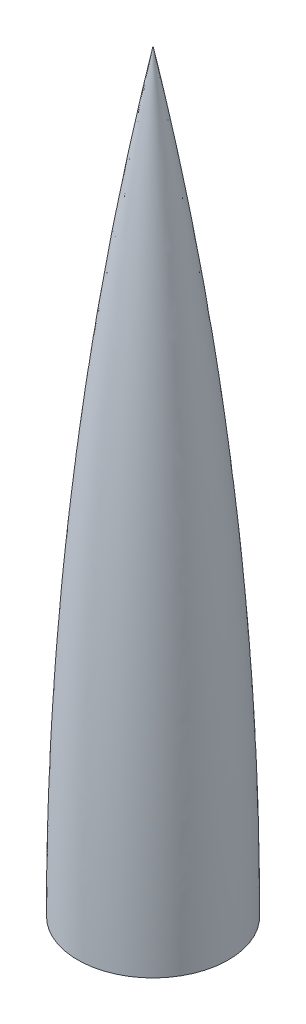
from build123d import *


with BuildPart() as part:
    # Sketch1 → Revolve1 (revolve)
    with BuildSketch(Plane(origin=(0, 0, 0), x_dir=(0, 0, -1), z_dir=(1, 0, 0))):
        with BuildLine():
            Line((76.2, 0), (78.359, 0))
            add(Edge.make_bspline(
                [(74.5236, 173.99), (77.07256008, 116.0310849), (78.349261293, 58.01558305), (78.359, 0)],
                knots=[0.779357411, 0.779357411, 0.779357411, 0.779357411, 1, 1, 1, 1], degree=3))
            Line((74.5236, 173.99), (72.834586455, 173.99))
            add(Edge.make_bspline(
                [(72.834586455, 173.99), (75.070189235, 115.962788806), (75.922551541, 57.867863687), (76.2, 0)],
                knots=[0.776751373, 0.776751373, 0.776751373, 0.776751373, 1, 1, 1, 1], degree=3))
        make_face()
        with BuildLine():
            Line((72.834586455, 173.99), (74.5236, 173.99))
            add(Edge.make_bspline(
                [(64.8716, 326.39), (69.070863692, 275.659016745), (72.28700433, 224.846292173), (74.5236, 173.99)],
                knots=[0.58575365, 0.58575365, 0.58575365, 0.58575365, 0.779357411, 0.779357411, 0.779357411, 0.779357411], degree=3))
            Line((64.8716, 326.39), (63.207975394, 326.39))
            add(Edge.make_bspline(
                [(63.207975394, 326.39), (67.846041191, 275.774919343), (70.87285844, 224.908529388), (72.834586455, 173.99)],
                knots=[0.580852043, 0.580852043, 0.580852043, 0.580852043, 0.776751373, 0.776751373, 0.776751373, 0.776751373], degree=3))
        make_face()
        with BuildLine():
            Line((63.207975394, 326.39), (64.8716, 326.39))
            add(Edge.make_bspline(
                [(49.276, 478.79), (55.456643265, 428.095639043), (60.65884645, 377.283953191), (64.8716, 326.39)],
                knots=[0.391527949, 0.391527949, 0.391527949, 0.391527949, 0.58575365, 0.58575365, 0.58575365, 0.58575365], degree=3))
            Line((49.276, 478.79), (45.677088337, 478.79))
            add(Edge.make_bspline(
                [(45.677088337, 478.79), (52.241832325, 428.00308453), (58.540705485, 377.323784294), (63.207975394, 326.39)],
                knots=[0.38371921, 0.38371921, 0.38371921, 0.38371921, 0.580852043, 0.580852043, 0.580852043, 0.580852043], degree=3))
        make_face()
        with BuildLine():
            Line((45.677088337, 478.79), (49.276, 478.79))
            add(Edge.make_bspline(
                [(23.495, 656.59), (33.433715014, 597.531543666), (42.027694502, 538.241451817), (49.276, 478.79)],
                knots=[0.163751138, 0.163751138, 0.163751138, 0.163751138, 0.391527949, 0.391527949, 0.391527949, 0.391527949], degree=3))
            Line((23.495, 656.59), (20.714159162, 656.59))
            add(Edge.make_bspline(
                [(20.714159162, 656.59), (21.636899539, 650.690493642), (30.761701099, 591.780379646), (38.766948962, 532.249002357), (45.677088337, 478.79)],
                knots=[0.153158413, 0.153158413, 0.153158413, 0.153158413, 0.176214493, 0.38371921, 0.38371921, 0.38371921, 0.38371921], degree=3))
        make_face()
        with BuildLine():
            Line((20.714159162, 656.59), (23.495, 656.59))
            add(Edge.make_bspline(
                [(9.906, 732.79), (14.681657927, 707.435014667), (19.213128689, 682.034004534), (23.495, 656.59)],
                knots=[0.065618634, 0.065618634, 0.065618634, 0.065618634, 0.163751138, 0.163751138, 0.163751138, 0.163751138], degree=3))
            Line((9.906, 732.79), (8.060127879, 732.79))
            add(Edge.make_bspline(
                [(8.060127879, 732.79), (12.189627588, 709.995264831), (16.344706011, 684.421026702), (20.318649784, 659.11867453), (20.714159162, 656.59)],
                knots=[0.054334345, 0.054334345, 0.054334345, 0.054334345, 0.143276006, 0.153158413, 0.153158413, 0.153158413, 0.153158413], degree=3))
        make_face()
        with BuildLine():
            Line((8.060127879, 732.79), (9.906, 732.79))
            add(Edge.make_bspline(
                [(0, 783.59), (3.41010332, 766.67784951), (6.712642709, 749.744214166), (9.906, 732.79)],
                knots=[0, 0, 0, 0, 0.065618634, 0.065618634, 0.065618634, 0.065618634], degree=3))
            Line((0, 783.59), (0, 774.216344916))
            add(Edge.make_bspline(
                [(0, 774.216344916), (2.869195373, 760.557669013), (5.53742186, 746.715274168), (8.060127879, 732.79)],
                knots=[0, 0, 0, 0, 0.054334345, 0.054334345, 0.054334345, 0.054334345], degree=3))
        make_face()
    revolve(axis=Axis((0, 0, 0), (0, 1, 0)))


solid = part.part
